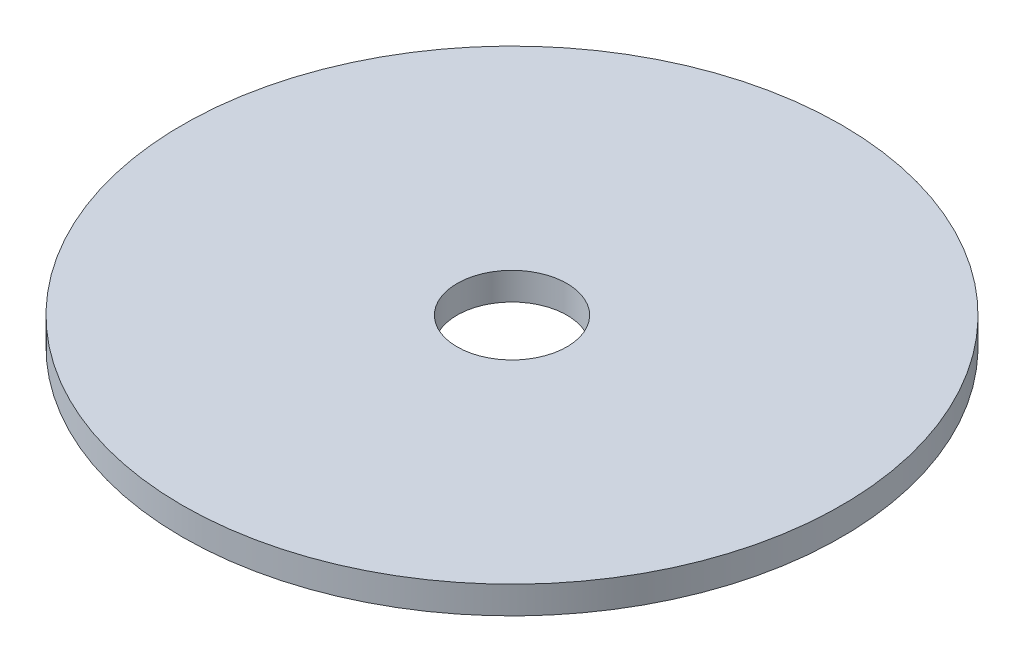
from build123d import *

# Parameters (mm, degrees)
SKETCH1_R           = 30
BOSS_EXTRUDE2_DEPTH = 2.5
SKETCH2_R           = 5
CUT_EXTRUDE2_DEPTH  = 2.5


with BuildPart() as part:
    # Sketch1 → Boss-Extrude2 (new body)
    with BuildSketch(Plane(origin=(0, 0, 0), x_dir=(1, 0, 0), z_dir=(0, 1, 0))):
        Circle(SKETCH1_R)
    extrude(amount=BOSS_EXTRUDE2_DEPTH)

    # Sketch2 → Cut-Extrude2 (cut)
    with BuildSketch(Plane(origin=(0, 2.5, 0), x_dir=(1, 0, 0), z_dir=(0, 1, 0))):
        Circle(SKETCH2_R)
    extrude(amount=-CUT_EXTRUDE2_DEPTH, mode=Mode.SUBTRACT)


solid = part.part
